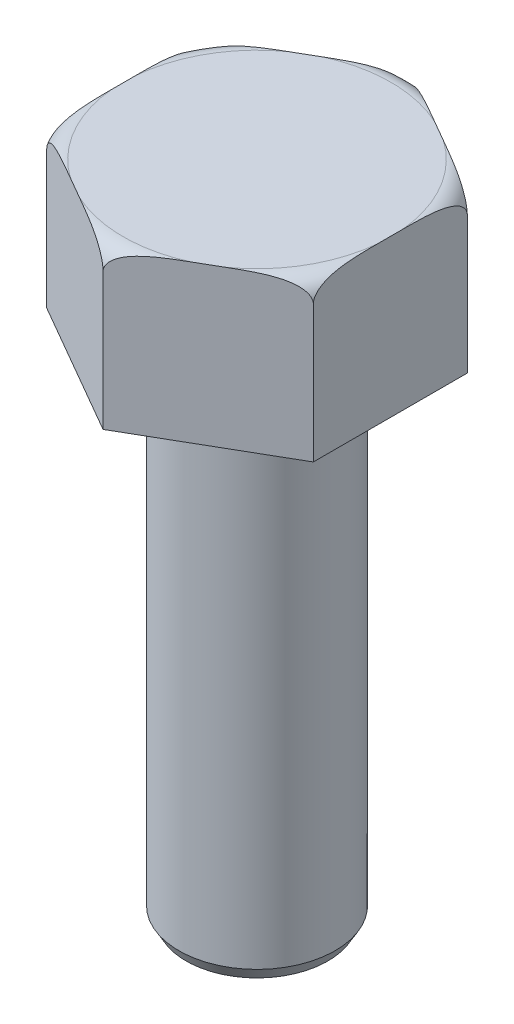
from build123d import *

# Parameters (mm, degrees)
BOSS_EXTRUDE1_DEPTH = 15.875
SKETCH6_R           = 7.9121
BOSS_EXTRUDE2_DEPTH = 50.8
CHAMFER1_SIZE       = 1.27
CHAMFER1_SIZE2      = 0.733234842


with BuildPart() as part:
    # Sketch1 → Boss-Extrude1 (new body)
    with BuildSketch(Plane(origin=(0, 0, 0), x_dir=(1, 0, 0), z_dir=(0, 1, 0))):
        Polygon((0, -15.58124039), (13.49375, -7.790620195), (13.49375, 7.790620195), (0, 15.58124039), (-13.49375, 7.790620195), (-13.49375, -7.790620195), align=None)
    extrude(amount=BOSS_EXTRUDE1_DEPTH)

    # Sketch2 → Cut-Revolve1 (revolve, cut)
    with BuildSketch(Plane(origin=(0, 0, 0), x_dir=(0, 0, -1), z_dir=(1, 0, 0))):
        with BuildLine():
            Line((13.54924039, 15.875), (15.58124039, 15.875))
            Line((15.58124039, 15.875), (15.58124039, 13.843))
            ThreePointArc((15.58124039, 13.843), (14.986081369, 15.279840979), (13.54924039, 15.875))
        make_face()
    revolve(axis=Axis((0, 15.875, 0), (0, -1, 0)), mode=Mode.SUBTRACT)

    # Sketch6 → Boss-Extrude2 (add)
    with BuildSketch(Plane.XZ):
        Circle(SKETCH6_R)
    extrude(amount=BOSS_EXTRUDE2_DEPTH)

    # Chamfer1
    chamfer1_edges = [part.edges().sort_by_distance(p)[0] for p in [
        (-7.9121, -50.8, 0),
    ]]
    chamfer1_side = [part.faces().sort_by_distance(p)[0] for p in [
        (-7.9121, -25.4, 0),
    ]]
    chamfer(chamfer1_edges, length=CHAMFER1_SIZE, length2=CHAMFER1_SIZE2, reference=chamfer1_side[0])


solid = part.part
